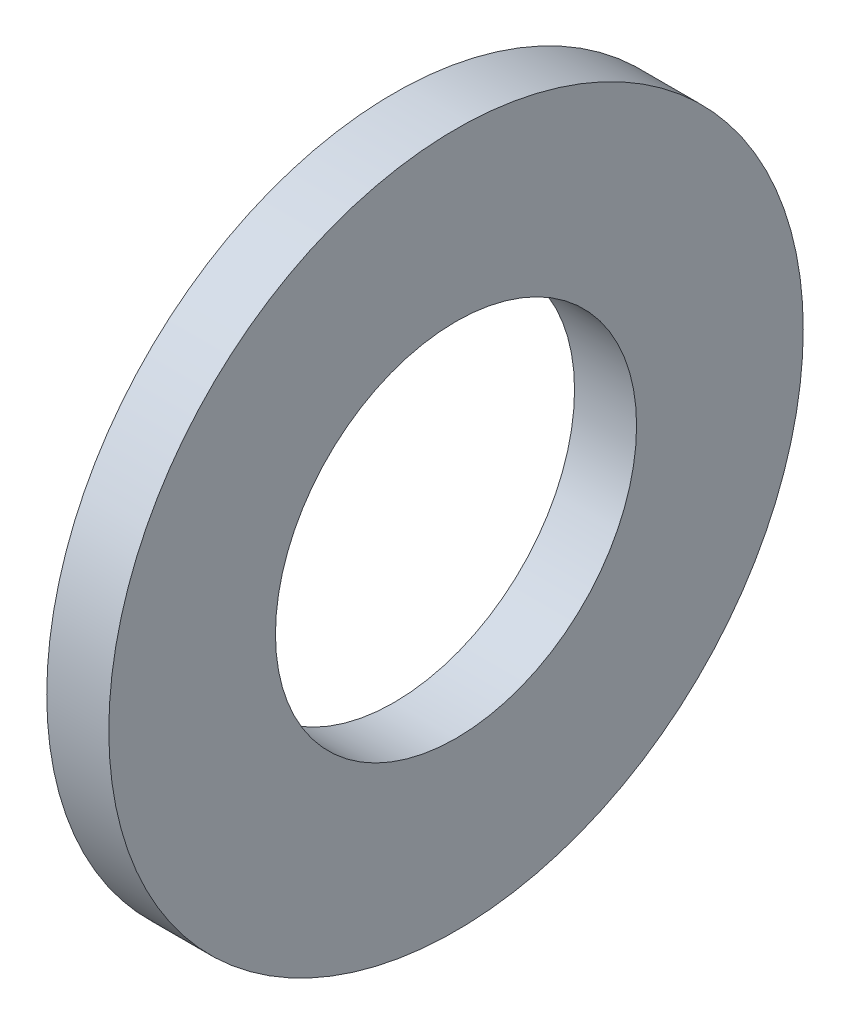
from build123d import *

# Parameters (mm, degrees)
SKETCH1_R           = 9.525
SKETCH1_R_2         = 4.953
BOSS_EXTRUDE1_DEPTH = 1.7018


with BuildPart() as part:
    # Sketch1 → Boss-Extrude1 (new body)
    with BuildSketch(Plane(origin=(0, 0, 0), x_dir=(0, 0, -1), z_dir=(1, 0, 0))):
        Circle(SKETCH1_R)
        Circle(SKETCH1_R_2, mode=Mode.SUBTRACT)
    extrude(amount=BOSS_EXTRUDE1_DEPTH)


solid = part.part
